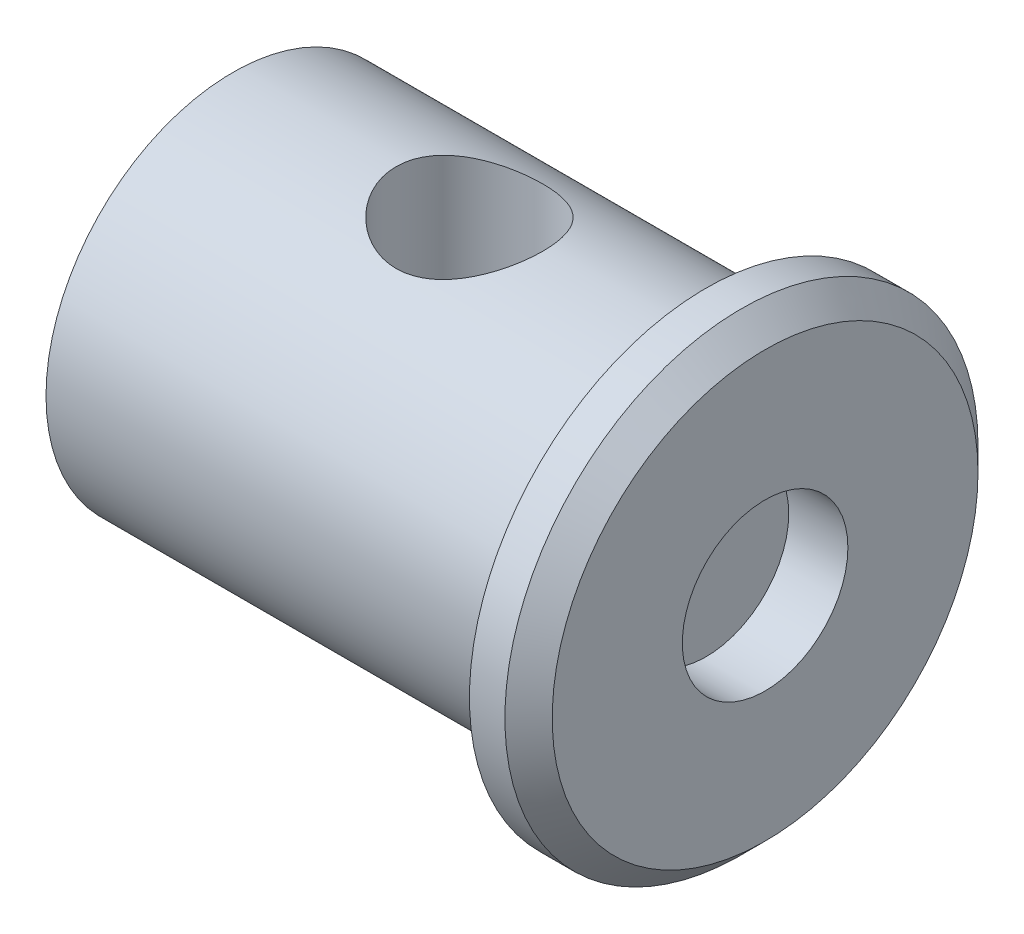
from build123d import *

# Parameters (mm, degrees)
SKETCH_1_R          = 7.9
EXTRUDE_1_DEPTH     = 20
SKETCH_5_R          = 3.1
CUT_EXTRUDE_2_DEPTH = 20
SKETCH_6_R          = 10
EXTRUDE_2_DEPTH     = 2.5
SKETCH_7_R          = 3.5
CUT_EXTRUDE_3_DEPTH = 2.5
CHAMFER_1_SIZE      = 1


with BuildPart() as part:
    # 草图1 → 凸台-拉伸1 (new body)
    with BuildSketch(Plane(origin=(0, 0, 0), x_dir=(0, 0, -1), z_dir=(1, 0, 0))):
        Circle(SKETCH_1_R)
    extrude(amount=-EXTRUDE_1_DEPTH)

    # 草图5 → 切除-拉伸2 (cut, symmetric)
    with BuildSketch(Plane(origin=(0, 0, 0), x_dir=(1, 0, 0), z_dir=(0, 1, 0))):
        with Locations((-10, 0)):
            Circle(SKETCH_5_R)
    extrude(amount=CUT_EXTRUDE_2_DEPTH, both=True, mode=Mode.SUBTRACT)

    # 草图6 → 凸台-拉伸2 (add)
    with BuildSketch(Plane(origin=(0, 0, 0), x_dir=(0, 0, -1), z_dir=(1, 0, 0))):
        Circle(SKETCH_6_R)
    extrude(amount=EXTRUDE_2_DEPTH)

    # 草图7 → 切除-拉伸3 (cut)
    with BuildSketch(Plane(origin=(2.5, 0, 0), x_dir=(0, 0, -1), z_dir=(1, 0, 0))):
        Circle(SKETCH_7_R)
    extrude(amount=-CUT_EXTRUDE_3_DEPTH, mode=Mode.SUBTRACT)

    # 倒角1
    chamfer_1_edges = [part.edges().sort_by_distance(p)[0] for p in [
        (2.5, 0, 10),
    ]]
    chamfer(chamfer_1_edges, length=CHAMFER_1_SIZE)


solid = part.part
